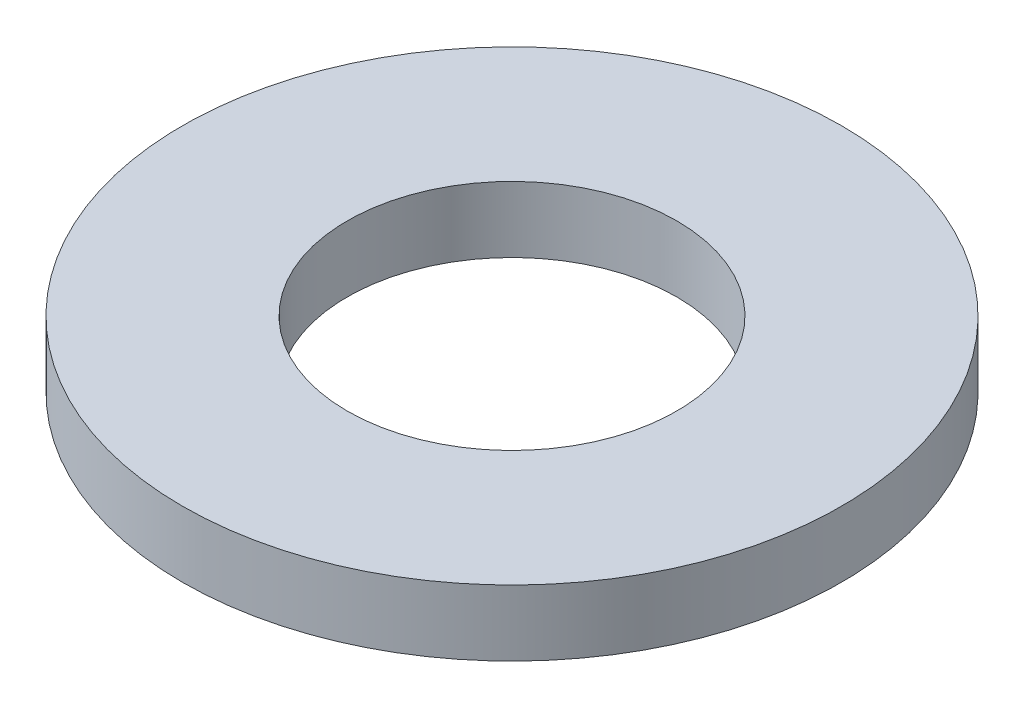
from build123d import *

# Parameters (mm, degrees)
ESQUISSE1_R        = 5
ESQUISSE1_R_2      = 2.5
BOSS_EXTRU_1_DEPTH = 1


with BuildPart() as part:
    # Esquisse1 → Boss.-Extru.1 (new body)
    with BuildSketch(Plane(origin=(0, 0, 0), x_dir=(1, 0, 0), z_dir=(0, 1, 0))):
        Circle(ESQUISSE1_R)
        Circle(ESQUISSE1_R_2, mode=Mode.SUBTRACT)
    extrude(amount=BOSS_EXTRU_1_DEPTH)


solid = part.part
